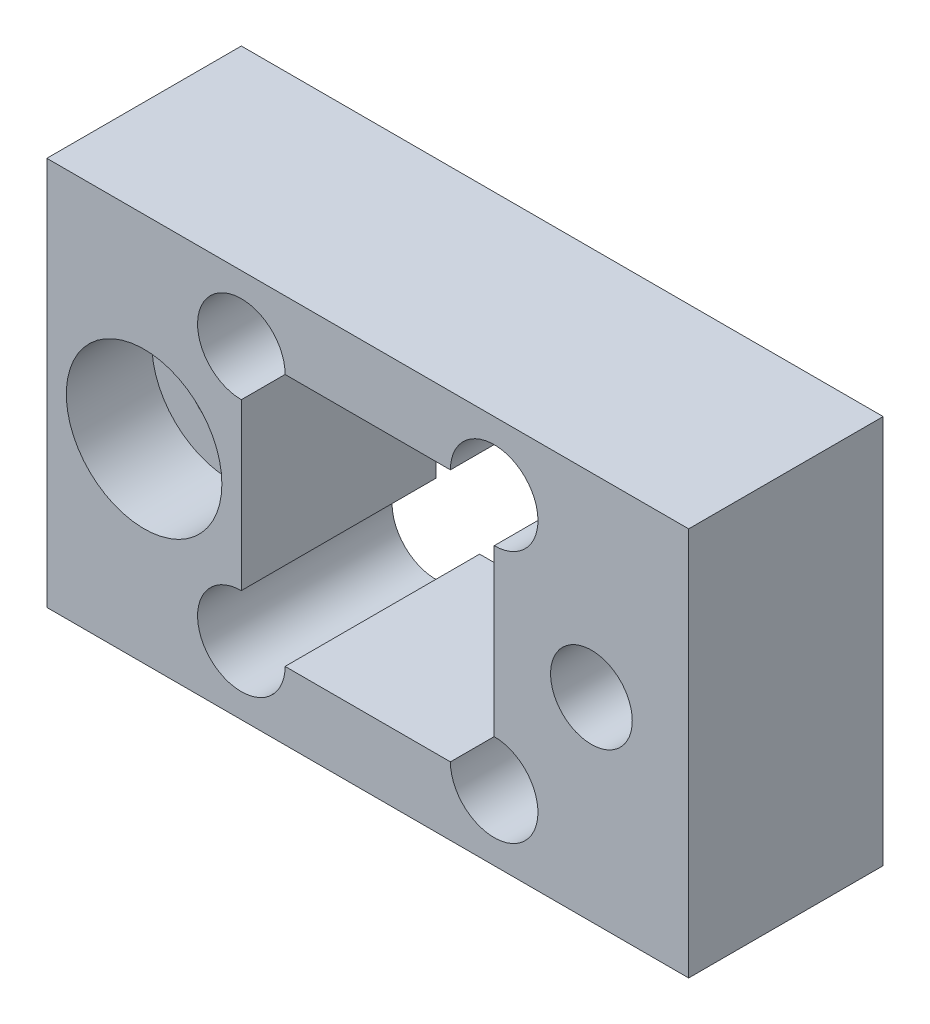
from build123d import *

# Parameters (mm, degrees)
SKIZZE1_W                                            = 33
SKIZZE1_H                                            = 20
SKIZZE1_W_2                                          = 13
SKIZZE1_H_2                                          = 13
AUFSATZ_LINEAR_AUSTRAGEN1_DEPTH                      = 10
STIRNSENKUNG_F_R_M4_ZYLINDERSCHRAUBE_MIT_D           = 4.5
STIRNSENKUNG_F_R_M4_ZYLINDERSCHRAUBE_MIT_CBORE_D     = 8
STIRNSENKUNG_F_R_M4_ZYLINDERSCHRAUBE_MIT_CBORE_DEPTH = 4.4
SKIZZE8_R                                            = 2.25
SCHNITT_LINEAR_AUSTRAGEN1_DEPTH                      = 11
M5_GEWINDEBOHRUNG1_D                                 = 4.2


with BuildPart() as part:
    # Skizze1 → Aufsatz-Linear austragen1 (new body)
    with BuildSketch(Plane.XY):
        Rectangle(SKIZZE1_W, SKIZZE1_H)
        Rectangle(SKIZZE1_W_2, SKIZZE1_H_2, mode=Mode.SUBTRACT)
    extrude(amount=AUFSATZ_LINEAR_AUSTRAGEN1_DEPTH)

    # Stirnsenkung für M4 Zylinderschraube mit Innensechskant1 (through all)
    with Locations(Plane.XY.offset(10)):
        with Locations((-11.5, 0)):
            CounterBoreHole(STIRNSENKUNG_F_R_M4_ZYLINDERSCHRAUBE_MIT_D / 2, STIRNSENKUNG_F_R_M4_ZYLINDERSCHRAUBE_MIT_CBORE_D / 2, STIRNSENKUNG_F_R_M4_ZYLINDERSCHRAUBE_MIT_CBORE_DEPTH)

    # Skizze8 → Schnitt-Linear austragen1 (cut, through all)
    with BuildSketch(Plane.XY.offset(10)):
        with Locations((-6.5, 6.5)):
            Circle(SKIZZE8_R)
        with Locations((-6.5, -6.5)):
            Circle(SKIZZE8_R)
        with Locations((6.5, -6.5)):
            Circle(SKIZZE8_R)
        with Locations((6.5, 6.5)):
            Circle(SKIZZE8_R)
    extrude(amount=-SCHNITT_LINEAR_AUSTRAGEN1_DEPTH, mode=Mode.SUBTRACT)

    # M5 Gewindebohrung1 (through all)
    with Locations(Plane.XY.offset(10)):
        with Locations((11.5, 0)):
            Hole(M5_GEWINDEBOHRUNG1_D / 2)


solid = part.part
